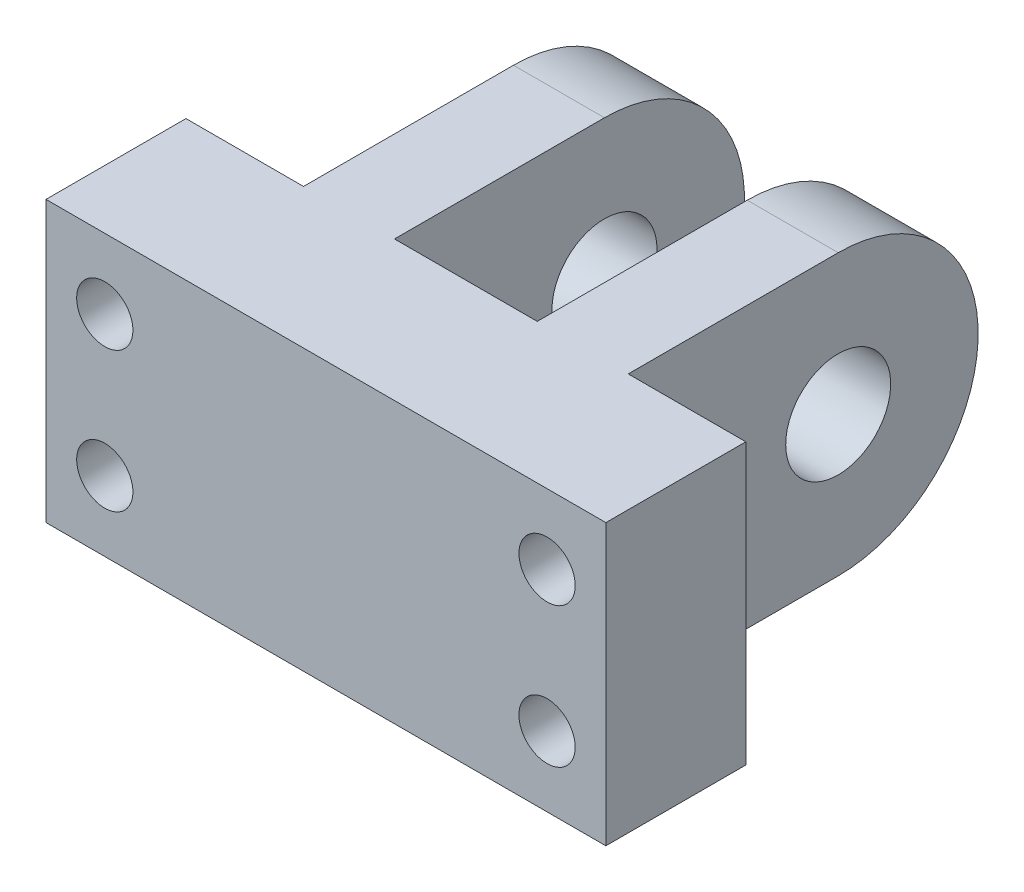
from build123d import *

# Parameters (mm, degrees)
SKETCH1_R                                       = 4.7625
BOSS_EXTRUDE1_DEPTH                             = 50.8
CUT_EXTRUDE1_DEPTH                              = 26.4
CBORE_FOR_10_SOCKET_HEAD_CAP_SCREW1_D           = 5.1054
CBORE_FOR_10_SOCKET_HEAD_CAP_SCREW1_CBORE_D     = 9.525
CBORE_FOR_10_SOCKET_HEAD_CAP_SCREW1_CBORE_DEPTH = 4.826


with BuildPart() as part:
    # Sketch1 → Boss-Extrude1 (new body)
    with BuildSketch(Plane(origin=(0, 0, 0), x_dir=(0, 0, -1), z_dir=(1, 0, 0))):
        with BuildLine():
            Line((0, 0), (31.75, 0))
            ThreePointArc((31.75, 0), (44.45, 12.7), (31.75, 25.4))
            Line((31.75, 25.4), (0, 25.4))
            Line((0, 25.4), (0, 0))
        make_face()
        with Locations((31.75, 12.7)):
            Circle(SKETCH1_R, mode=Mode.SUBTRACT)
    extrude(amount=BOSS_EXTRUDE1_DEPTH)

    # Sketch2 → Cut-Extrude1 (cut, through all)
    with BuildSketch(Plane.XZ):
        Polygon((50.8, -12.7), (40.132, -12.7), (40.132, -44.45), (31.877, -44.45), (31.877, -12.7), (18.923, -12.7), (18.923, -44.45), (10.668, -44.45), (10.668, -12.7), (0, -12.7), (0, -50.8), (50.8, -50.8), align=None)
    extrude(amount=-CUT_EXTRUDE1_DEPTH, mode=Mode.SUBTRACT)

    # CBORE for #10 Socket Head Cap Screw1 (through all)
    with Locations(Plane(origin=(0, 0, -12.7), x_dir=(-1, 0, 0), z_dir=(0, 0, -1))):
        with Locations((-45.466, 6.35), (-45.466, 19.05), (-5.334, 19.05), (-5.334, 6.35)):
            CounterBoreHole(CBORE_FOR_10_SOCKET_HEAD_CAP_SCREW1_D / 2, CBORE_FOR_10_SOCKET_HEAD_CAP_SCREW1_CBORE_D / 2, CBORE_FOR_10_SOCKET_HEAD_CAP_SCREW1_CBORE_DEPTH)


solid = part.part
